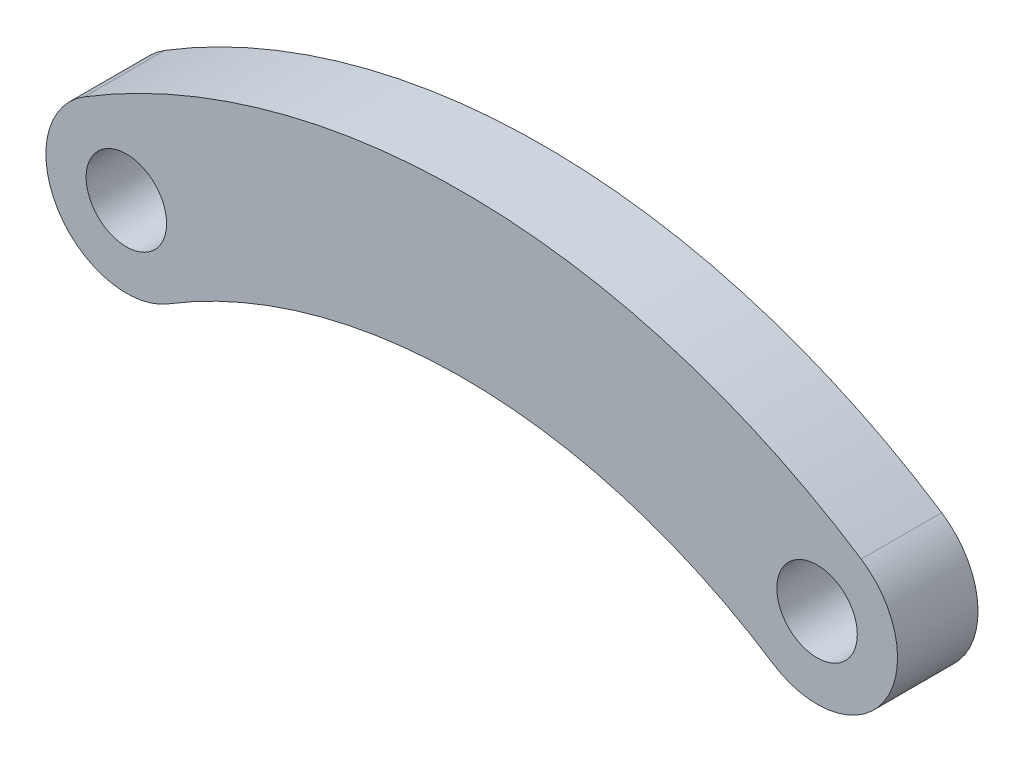
from build123d import *

# Parameters (mm, degrees)
SKETCH1_R           = 1.5
BOSS_EXTRUDE1_DEPTH = 3


with BuildPart() as part:
    # Sketch1 → Boss-Extrude1 (new body)
    with BuildSketch(Plane.XY):
        with BuildLine():
            ThreePointArc((16.667258487, 3.092264578), (2.252499278, 7.520108125), (-12.291231068, 3.536267122))
            ThreePointArc((-12.291231068, 3.536267122), (-13.280504589, -0.589425292), (-9.154812174, -1.578698813))
            ThreePointArc((-9.154812174, -1.578698813), (2.160515814, 1.520813246), (13.375501545, -1.924142128))
            ThreePointArc((13.375501545, -1.924142128), (17.529583369, -1.061817246), (16.667258487, 3.092264578))
        make_face()
        with Locations((-10.723021621, 0.978784155)):
            Circle(SKETCH1_R, mode=Mode.SUBTRACT)
        with Locations((15.021380016, 0.584061225)):
            Circle(SKETCH1_R, mode=Mode.SUBTRACT)
    extrude(amount=BOSS_EXTRUDE1_DEPTH)


solid = part.part
